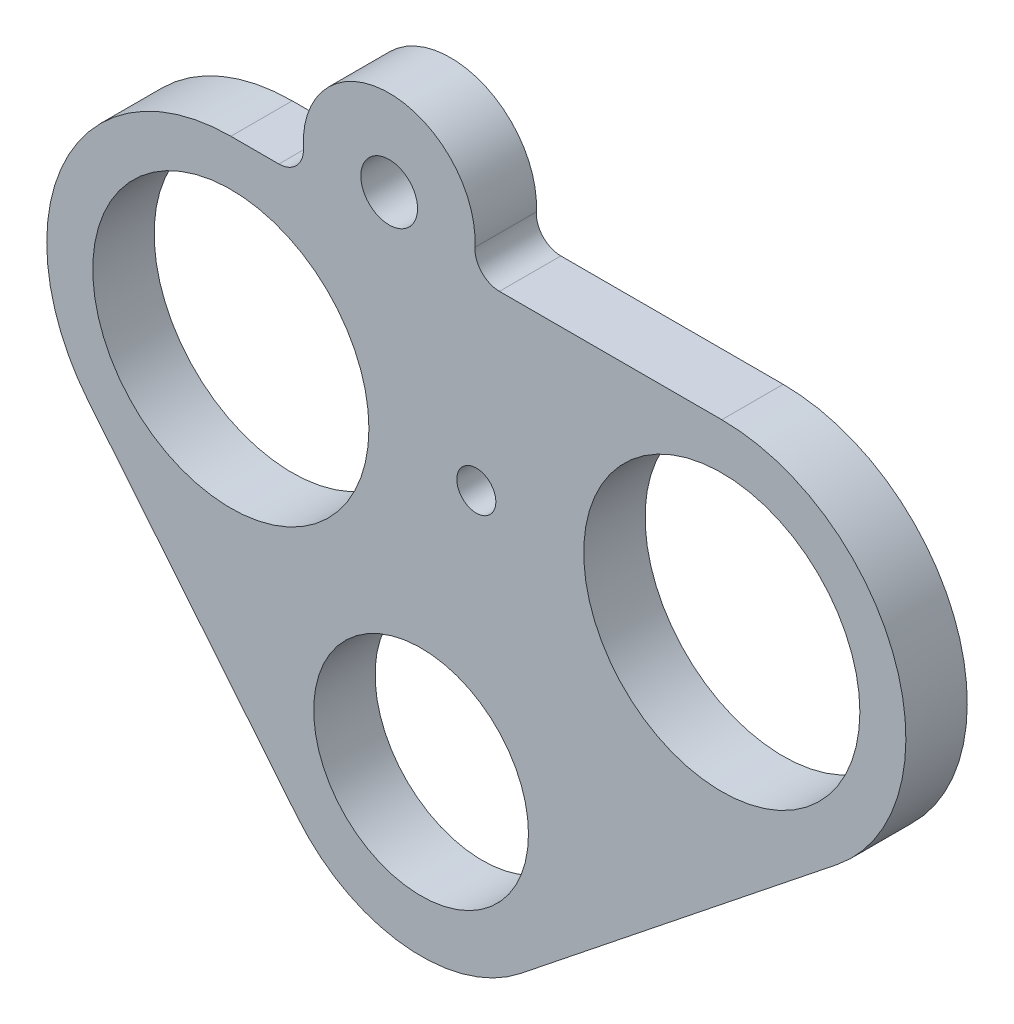
from build123d import *

# Parameters (mm, degrees)
SKETCH1_R                        = 2.9337
BOSS_EXTRUDE1_DEPTH              = 6.35
F_1_1_DIAMETER_HOLE1_D           = 28.575
F_1_1_DIAMETER_HOLE1_DEPTH       = 25.4
F_1_1_DIAMETER_HOLE1_TIP         = 8.584796094
F_7_8_0_875_DIAMETER_HOLE1_D     = 22.225
F_7_8_0_875_DIAMETER_HOLE1_DEPTH = 25.4
F_7_8_0_875_DIAMETER_HOLE1_TIP   = 6.677063629
TAP_DRILL_FOR_10_32_TAP1_D       = 4.0386
FILLET1_R                        = 2.54


with BuildPart() as part:
    # Sketch1 → Boss-Extrude1 (new body)
    with BuildSketch(Plane.XY):
        with BuildLine():
            Line((-11.605702487, 47.126767531), (-19.685, 47.126767531))
            ThreePointArc((-19.685, 47.126767531), (-36.899439748, 36.235539754), (-34.430269589, 16.015278206))
            Line((-34.430269589, 16.015278206), (-12.779233644, -10.453290749))
            ThreePointArc((-12.779233644, -10.453290749), (-1.744405346, -16.417586607), (10.297338688, -12.905228241))
            Line((10.297338688, -12.905228241), (42.996544639, 13.186119561))
            ThreePointArc((42.996544639, 13.186119561), (49.095118796, 34.371036995), (31.115, 47.126767531))
            Line((31.115, 47.126767531), (5.001702487, 47.126767531))
            ThreePointArc((5.001702487, 47.126767531), (-3.302, 59.191767531), (-11.605702487, 47.126767531))
        make_face()
        with Locations((-3.302, 50.301767531)):
            Circle(SKETCH1_R, mode=Mode.SUBTRACT)
    extrude(amount=BOSS_EXTRUDE1_DEPTH)

    # 1 (1) Diameter Hole1
    with Locations(Plane.XY.offset(6.35)):
        with Locations((-19.685, 28.076767531), (31.115, 28.076767531)):
            Hole(F_1_1_DIAMETER_HOLE1_D / 2, depth=F_1_1_DIAMETER_HOLE1_DEPTH)
            with Locations((0, 0, -(F_1_1_DIAMETER_HOLE1_DEPTH + F_1_1_DIAMETER_HOLE1_TIP / 2))):  # 118° drill point
                Cone(0, F_1_1_DIAMETER_HOLE1_D / 2, F_1_1_DIAMETER_HOLE1_TIP, mode=Mode.SUBTRACT)

    # 7/8 (0.875) Diameter Hole1
    with Locations(Plane.XY.offset(6.35)):
        with Locations((0, 0)):
            Hole(F_7_8_0_875_DIAMETER_HOLE1_D / 2, depth=F_7_8_0_875_DIAMETER_HOLE1_DEPTH)
            with Locations((0, 0, -(F_7_8_0_875_DIAMETER_HOLE1_DEPTH + F_7_8_0_875_DIAMETER_HOLE1_TIP / 2))):  # 118° drill point
                Cone(0, F_7_8_0_875_DIAMETER_HOLE1_D / 2, F_7_8_0_875_DIAMETER_HOLE1_TIP, mode=Mode.SUBTRACT)

    # Tap Drill for #10-32 Tap1 (through all)
    with Locations(Plane.XY.offset(6.35)):
        with Locations((5.715, 28.076767531)):
            Hole(TAP_DRILL_FOR_10_32_TAP1_D / 2)

    # Fillet1
    fillet1_edges = [part.edges().sort_by_distance(p)[0] for p in [
        (5.001702487, 47.126767531, 3.175),
        (-11.605702487, 47.126767531, 3.175),
    ]]
    fillet(fillet1_edges, radius=FILLET1_R)


solid = part.part
